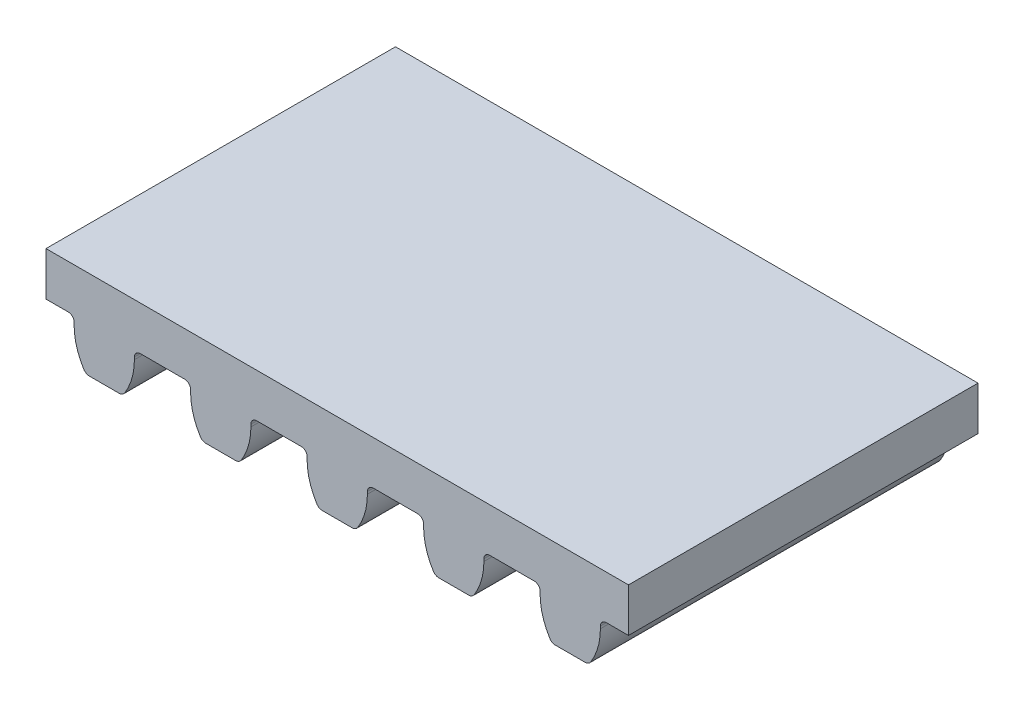
from build123d import *

# Parameters (mm, degrees)
EXTRUDE1_DEPTH = 15


with BuildPart() as part:
    # Sketch1 → Extrude1 (new body)
    with BuildSketch(Plane.XY.offset(15)):
        with BuildLine():
            Line((-14.551292676, 3.97958199), (-14.551292676, 4.079606381))
            ThreePointArc((-14.551292676, 4.079606381), (-14.476897799, 4.259211503), (-14.297292676, 4.333606381))
            Line((-14.297292676, 4.333606381), (-12.393373616, 4.333606381))
            ThreePointArc((-12.393373616, 4.333606381), (-12.213768494, 4.259211503), (-12.139373616, 4.079606381))
            Line((-12.139373616, 4.079606381), (-12.139373616, 3.97958199))
            ThreePointArc((-12.139373616, 3.97958199), (-12.032339909, 3.226505542), (-11.719716097, 2.533074433))
            ThreePointArc((-11.719716097, 2.533074433), (-11.618392315, 2.437817098), (-11.483697969, 2.403206381))
            Line((-11.483697969, 2.403206381), (-10.206978323, 2.403206381))
            ThreePointArc((-10.206978323, 2.403206381), (-10.072283977, 2.437817098), (-9.970960196, 2.533074433))
            ThreePointArc((-9.970960196, 2.533074433), (-9.658336383, 3.226505542), (-9.551302676, 3.97958199))
            Line((-9.551302676, 3.97958199), (-9.551302676, 4.079606381))
            ThreePointArc((-9.551302676, 4.079606381), (-9.476907799, 4.259211503), (-9.297302676, 4.333606381))
            Line((-9.297302676, 4.333606381), (-7.393383616, 4.333606381))
            ThreePointArc((-7.393383616, 4.333606381), (-7.213778494, 4.259211503), (-7.139383616, 4.079606381))
            Line((-7.139383616, 4.079606381), (-7.139383616, 3.97958199))
            ThreePointArc((-7.139383616, 3.97958199), (-7.032349909, 3.226505542), (-6.719726097, 2.533074433))
            ThreePointArc((-6.719726097, 2.533074433), (-6.618402315, 2.437817098), (-6.483707969, 2.403206381))
            Line((-6.483707969, 2.403206381), (-5.206988323, 2.403206381))
            ThreePointArc((-5.206988323, 2.403206381), (-5.072293977, 2.437817098), (-4.970970196, 2.533074433))
            ThreePointArc((-4.970970196, 2.533074433), (-4.658346383, 3.226505542), (-4.551312676, 3.97958199))
            Line((-4.551312676, 3.97958199), (-4.551312676, 4.079606381))
            ThreePointArc((-4.551312676, 4.079606381), (-4.476917799, 4.259211503), (-4.297312676, 4.333606381))
            Line((-4.297312676, 4.333606381), (-2.393393616, 4.333606381))
            ThreePointArc((-2.393393616, 4.333606381), (-2.213788494, 4.259211503), (-2.139393616, 4.079606381))
            Line((-2.139393616, 4.079606381), (-2.139393616, 3.97958199))
            ThreePointArc((-2.139393616, 3.97958199), (-2.032359909, 3.226505542), (-1.719736097, 2.533074433))
            ThreePointArc((-1.719736097, 2.533074433), (-1.618412315, 2.437817098), (-1.483717969, 2.403206381))
            Line((-1.483717969, 2.403206381), (-0.206998323, 2.403206381))
            ThreePointArc((-0.206998323, 2.403206381), (-0.072303977, 2.437817098), (0.029019804, 2.533074433))
            ThreePointArc((0.029019804, 2.533074433), (0.341643617, 3.226505542), (0.448677324, 3.97958199))
            Line((0.448677324, 3.97958199), (0.448677324, 4.079606381))
            ThreePointArc((0.448677324, 4.079606381), (0.523072201, 4.259211503), (0.702677324, 4.333606381))
            Line((0.702677324, 4.333606381), (2.606596384, 4.333606381))
            ThreePointArc((2.606596384, 4.333606381), (2.786201506, 4.259211503), (2.860596384, 4.079606381))
            Line((2.860596384, 4.079606381), (2.860596384, 3.97958199))
            ThreePointArc((2.860596384, 3.97958199), (2.967630091, 3.226505542), (3.280253903, 2.533074433))
            ThreePointArc((3.280253903, 2.533074433), (3.381577685, 2.437817098), (3.516272031, 2.403206381))
            Line((3.516272031, 2.403206381), (4.792991677, 2.403206381))
            ThreePointArc((4.792991677, 2.403206381), (4.927686023, 2.437817098), (5.029009804, 2.533074433))
            ThreePointArc((5.029009804, 2.533074433), (5.341633617, 3.226505542), (5.448667324, 3.97958199))
            Line((5.448667324, 3.97958199), (5.448667324, 4.079606381))
            ThreePointArc((5.448667324, 4.079606381), (5.523062201, 4.259211503), (5.702667324, 4.333606381))
            Line((5.702667324, 4.333606381), (6.654626854, 4.333606381))
            Line((6.654626854, 4.333606381), (6.654626854, 6.213206381))
            Line((6.654626854, 6.213206381), (-18.345323146, 6.213206381))
            Line((-18.345323146, 6.213206381), (-18.345323146, 4.333606381))
            Line((-18.345323146, 4.333606381), (-17.393363616, 4.333606381))
            ThreePointArc((-17.393363616, 4.333606381), (-17.213758494, 4.259211503), (-17.139363616, 4.079606381))
            Line((-17.139363616, 4.079606381), (-17.139363616, 3.97958199))
            ThreePointArc((-17.139363616, 3.97958199), (-17.032329909, 3.226505542), (-16.719706097, 2.533074433))
            ThreePointArc((-16.719706097, 2.533074433), (-16.618382315, 2.437817098), (-16.483687969, 2.403206381))
            Line((-16.483687969, 2.403206381), (-15.206968323, 2.403206381))
            ThreePointArc((-15.206968323, 2.403206381), (-15.072273977, 2.437817098), (-14.970950196, 2.533074433))
            ThreePointArc((-14.970950196, 2.533074433), (-14.658326383, 3.226505542), (-14.551292676, 3.97958199))
        make_face()
    extrude(amount=-EXTRUDE1_DEPTH)


solid = part.part
